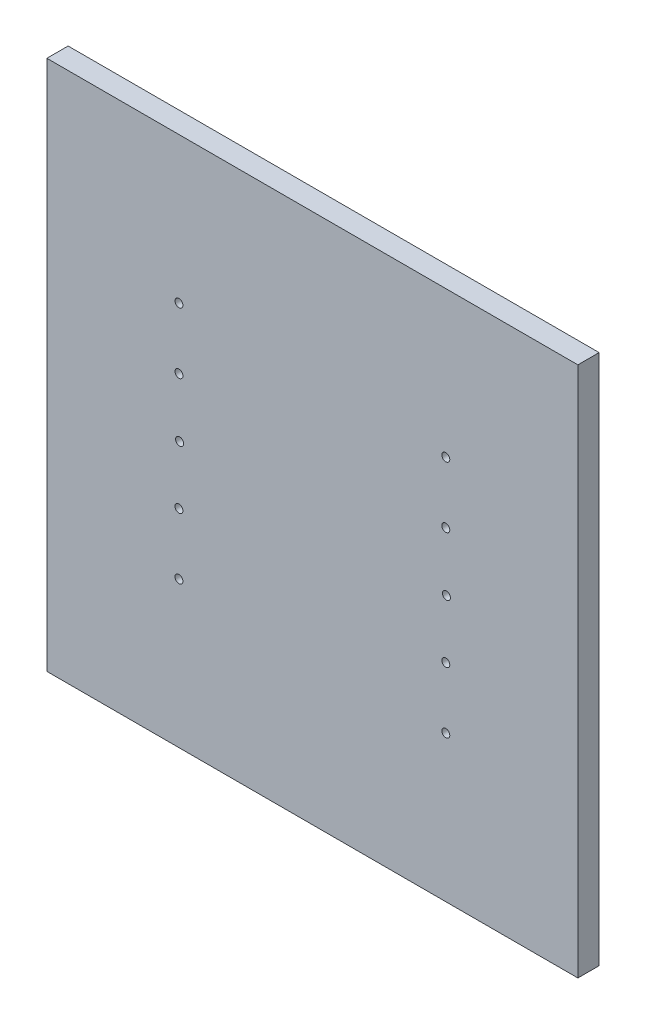
from build123d import *

# Parameters (mm, degrees)
SKETCH1_W                               = 200
SKETCH1_H                               = 200
BOSS_EXTRUDE1_DEPTH                     = 8
CBORE_FOR_M2_PAN_HEAD_SCREW1_AT_2_COUNT = 2
CBORE_FOR_M2_PAN_HEAD_SCREW1_AT_2_PITCH = 89.990465529
CBORE_FOR_M2_PAN_HEAD_SCREW1_AT_3_COUNT = 2
CBORE_FOR_M2_PAN_HEAD_SCREW1_AT_3_PITCH = 89.990465529
CBORE_FOR_M2_PAN_HEAD_SCREW1_AT_4_COUNT = 2
CBORE_FOR_M2_PAN_HEAD_SCREW1_AT_4_PITCH = 66.987356945
CBORE_FOR_M2_PAN_HEAD_SCREW1_AT_5_COUNT = 2
CBORE_FOR_M2_PAN_HEAD_SCREW1_AT_5_PITCH = 23.002979742
SKETCH7_R                               = 2.5
CUT_EXTRUDE1_DEPTH                      = 4
SKETCH9_R                               = 1.5
CUT_EXTRUDE2_DEPTH                      = 10
LPATTERN1_COUNT                         = 2
LPATTERN1_PITCH                         = 100.5


with BuildPart() as part:
    # Sketch1 → Boss-Extrude1 (new body)
    with BuildSketch(Plane.XY):
        with Locations((100, 100)):
            Rectangle(SKETCH1_W, SKETCH1_H)
    extrude(amount=BOSS_EXTRUDE1_DEPTH)

    # Sketch6 → CBORE for M2 Pan Head Screw1 (revolve, cut)
    with BuildSketch(Plane(origin=(49.75, 55.009534471, 0), x_dir=(0, 1, 0), z_dir=(1, 0, 0))):
        Polygon((0, 0), (0, 8.901290929), (1.5, 8), (1.5, 4), (2.5, 4), (2.5, 0), align=None)
    cbore_for_m2_pan_head_screw1 = revolve(axis=Axis((49.75, 55.009534471, -6.35), (0, 0, 1)), mode=Mode.SUBTRACT)

    # CBORE for M2 Pan Head Screw1 at 2: CBORE for M2 Pan Head Screw1 ×2
    with Locations(*[(0, i * CBORE_FOR_M2_PAN_HEAD_SCREW1_AT_2_PITCH, 0) for i in range(1, CBORE_FOR_M2_PAN_HEAD_SCREW1_AT_2_COUNT)]):
        add(cbore_for_m2_pan_head_screw1, mode=Mode.SUBTRACT)

    # CBORE for M2 Pan Head Screw1 at 3: CBORE for M2 Pan Head Screw1 ×2
    with Locations(*[(0, i * CBORE_FOR_M2_PAN_HEAD_SCREW1_AT_3_PITCH, 0) for i in range(1, CBORE_FOR_M2_PAN_HEAD_SCREW1_AT_3_COUNT)]):
        add(cbore_for_m2_pan_head_screw1, mode=Mode.SUBTRACT)

    # CBORE for M2 Pan Head Screw1 at 4: CBORE for M2 Pan Head Screw1 ×2
    with Locations(*[(0, i * CBORE_FOR_M2_PAN_HEAD_SCREW1_AT_4_PITCH, 0) for i in range(1, CBORE_FOR_M2_PAN_HEAD_SCREW1_AT_4_COUNT)]):
        add(cbore_for_m2_pan_head_screw1, mode=Mode.SUBTRACT)

    # CBORE for M2 Pan Head Screw1 at 5: CBORE for M2 Pan Head Screw1 ×2
    with Locations(*[(0, i * CBORE_FOR_M2_PAN_HEAD_SCREW1_AT_5_PITCH, 0) for i in range(1, CBORE_FOR_M2_PAN_HEAD_SCREW1_AT_5_COUNT)]):
        add(cbore_for_m2_pan_head_screw1, mode=Mode.SUBTRACT)

    # Sketch7 → Cut-Extrude1 (cut)
    with BuildSketch(Plane(origin=(0, 0, 0), x_dir=(-1, 0, 0), z_dir=(0, 0, -1))):
        with Locations((-50, 100)):
            Circle(SKETCH7_R)
    cut_extrude1 = extrude(amount=-CUT_EXTRUDE1_DEPTH, mode=Mode.SUBTRACT)

    # Sketch9 → Cut-Extrude2 (cut)
    with BuildSketch(Plane(origin=(0, 0, 4), x_dir=(-1, 0, 0), z_dir=(0, 0, -1))):
        with Locations((-50, 100)):
            Circle(SKETCH9_R)
    cut_extrude2 = extrude(amount=-CUT_EXTRUDE2_DEPTH, mode=Mode.SUBTRACT)

    # LPattern1: CBORE for M2 Pan Head Screw1, Cut-Extrude1, Cut-Extrude2 ×2
    with Locations(*[(i * LPATTERN1_PITCH, 0, 0) for i in range(1, LPATTERN1_COUNT)]):
        add(cbore_for_m2_pan_head_screw1, mode=Mode.SUBTRACT)
        add(cut_extrude1, mode=Mode.SUBTRACT)
        add(cut_extrude2, mode=Mode.SUBTRACT)

    # LPattern1 copy 1 sketch → LPattern1 copy 1 (revolve, cut)
    with BuildSketch(Plane(origin=(150.25, 145, 0), x_dir=(0, 1, 0), z_dir=(1, 0, 0))):
        Polygon((0, 0), (0, 8.901290929), (1.5, 8), (1.5, 4), (2.5, 4), (2.5, 0), align=None)
    revolve(axis=Axis((150.25, 145, -6.35), (0, 0, 1)), mode=Mode.SUBTRACT)

    # LPattern1 copy 2 sketch → LPattern1 copy 2 (revolve, cut)
    with BuildSketch(Plane(origin=(150.25, 145, 0), x_dir=(0, 1, 0), z_dir=(1, 0, 0))):
        Polygon((0, 0), (0, 8.901290929), (1.5, 8), (1.5, 4), (2.5, 4), (2.5, 0), align=None)
    revolve(axis=Axis((150.25, 145, -6.35), (0, 0, 1)), mode=Mode.SUBTRACT)

    # LPattern1 copy 3 sketch → LPattern1 copy 3 (revolve, cut)
    with BuildSketch(Plane(origin=(150.25, 121.996891416, 0), x_dir=(0, 1, 0), z_dir=(1, 0, 0))):
        Polygon((0, 0), (0, 8.901290929), (1.5, 8), (1.5, 4), (2.5, 4), (2.5, 0), align=None)
    revolve(axis=Axis((150.25, 121.996891416, -6.35), (0, 0, 1)), mode=Mode.SUBTRACT)

    # LPattern1 copy 4 sketch → LPattern1 copy 4 (revolve, cut)
    with BuildSketch(Plane(origin=(150.25, 78.012514213, 0), x_dir=(0, 1, 0), z_dir=(1, 0, 0))):
        Polygon((0, 0), (0, 8.901290929), (1.5, 8), (1.5, 4), (2.5, 4), (2.5, 0), align=None)
    revolve(axis=Axis((150.25, 78.012514213, -6.35), (0, 0, 1)), mode=Mode.SUBTRACT)


solid = part.part
